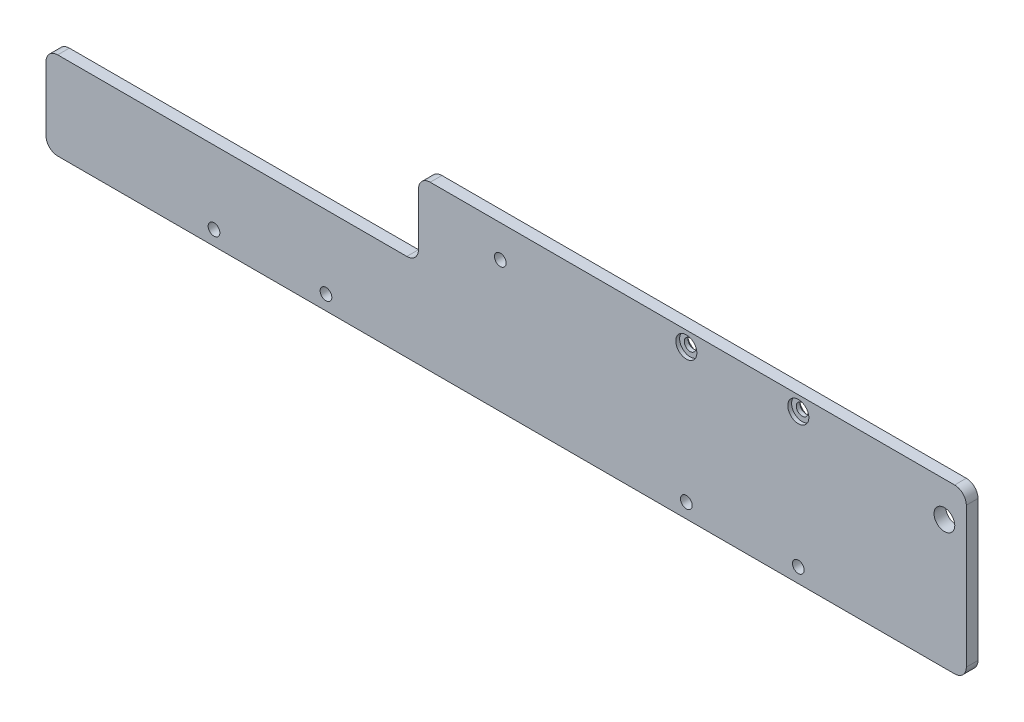
from build123d import *

# Parameters (mm, degrees)
SKETCH_1_R          = 2
SKETCH_1_R_2        = 3.55
EXTRUDE_1_DEPTH     = 4
EXTRUDE_3_DEPTH     = 4
SKETCH_3_R          = 3.6
CUT_EXTRUDE_1_DEPTH = 1.4
SKETCH_7_R          = 2
CUT_EXTRUDE_2_DEPTH = 10
SKETCH_8_R          = 3.6
CUT_EXTRUDE_3_DEPTH = 1.3


with BuildPart() as part:
    # 草图1 → 凸台-拉伸1 (new body)
    with BuildSketch(Plane.XY):
        with BuildLine():
            Line((-180.694062755, -12.410089261), (126.305937245, -12.410089261))
            ThreePointArc((126.305937245, -12.410089261), (129.13436437, -11.238516386), (130.305937245, -8.410089261))
            Line((130.305937245, -8.410089261), (130.305937245, 7.71191214))
            Line((130.305937245, 7.71191214), (130.305937245, 17.589910739))
            Line((130.305937245, 17.589910739), (130.305937245, 39.589910739))
            ThreePointArc((130.305937245, 39.589910739), (129.13436437, 42.418337863), (126.305937245, 43.589910739))
            Line((126.305937245, 43.589910739), (-23.194062755, 43.589910739))
            ThreePointArc((-23.194062755, 43.589910739), (-26.022489879, 42.418337863), (-27.194062755, 39.589910739))
            Line((-27.194062755, 39.589910739), (-27.194062755, 27.589910739))
            ThreePointArc((-27.194062755, 27.589910739), (-30.122994943, 20.518842927), (-37.194062755, 17.589910739))
            Line((-37.194062755, 17.589910739), (-180.694062755, 17.589910739))
            ThreePointArc((-180.694062755, 17.589910739), (-183.522489879, 16.418337863), (-184.694062755, 13.589910739))
            Line((-184.694062755, 13.589910739), (-184.694062755, -8.410089261))
            ThreePointArc((-184.694062755, -8.410089261), (-183.522489879, -11.238516386), (-180.694062755, -12.410089261))
        make_face()
        with Locations((-127.194062755, -7.410089261)):
            Circle(SKETCH_1_R, mode=Mode.SUBTRACT)
        with Locations((-88.864062755, -7.410089261)):
            Circle(SKETCH_1_R, mode=Mode.SUBTRACT)
        with Locations((34.475937245, -7.410089261)):
            Circle(SKETCH_1_R, mode=Mode.SUBTRACT)
        with Locations((72.805937245, -7.410089261)):
            Circle(SKETCH_1_R, mode=Mode.SUBTRACT)
        with Locations((34.475937245, 38.589910739)):
            Circle(SKETCH_1_R, mode=Mode.SUBTRACT)
        with Locations((122.805937245, 31.589910739)):
            Circle(SKETCH_1_R_2, mode=Mode.SUBTRACT)
        with Locations((72.805937245, 38.589910739)):
            Circle(SKETCH_1_R, mode=Mode.SUBTRACT)
    extrude(amount=EXTRUDE_1_DEPTH)

    # 草图2 → 凸台-拉伸3 (add)
    with BuildSketch(Plane(origin=(0, 0, 0), x_dir=(-1, 0, 0), z_dir=(0, 0, -1))):
        with BuildLine():
            Line((53.194062755, 43.589910739), (23.194062755, 43.589910739))
            Line((23.194062755, 43.589910739), (23.194062755, 17.589910739))
            Line((23.194062755, 17.589910739), (57.194062755, 17.589910739))
            Line((57.194062755, 17.589910739), (61.194062755, 17.589910739))
            ThreePointArc((61.194062755, 17.589910739), (58.36563563, 18.761483614), (57.194062755, 21.589910739))
            Line((57.194062755, 21.589910739), (57.194062755, 39.589910739))
            ThreePointArc((57.194062755, 39.589910739), (56.022489879, 42.418337863), (53.194062755, 43.589910739))
        make_face()
    extrude(amount=-EXTRUDE_3_DEPTH)

    # 草图3 → 切除-拉伸1 (cut)
    with BuildSketch(Plane(origin=(0, 0, 0), x_dir=(-1, 0, 0), z_dir=(0, 0, -1))):
        with Locations((-72.805937245, 38.589910739)):
            Circle(SKETCH_3_R)
        with Locations((-34.475937245, 38.589910739)):
            Circle(SKETCH_3_R)
    extrude(amount=-CUT_EXTRUDE_1_DEPTH, mode=Mode.SUBTRACT)

    # 草图7 → 切除-拉伸2 (cut)
    with BuildSketch(Plane(origin=(0, 0, 0), x_dir=(-1, 0, 0), z_dir=(0, 0, -1))):
        with Locations((29.194062755, 32.589910739)):
            Circle(SKETCH_7_R)
    extrude(amount=-CUT_EXTRUDE_2_DEPTH, mode=Mode.SUBTRACT)

    # 草图8 → 切除-拉伸3 (cut)
    with BuildSketch(Plane.XY.offset(4)):
        with Locations((72.805937245, 38.589910739)):
            Circle(SKETCH_8_R)
        with Locations((34.475937245, 38.589910739)):
            Circle(SKETCH_8_R)
    extrude(amount=-CUT_EXTRUDE_3_DEPTH, mode=Mode.SUBTRACT)


solid = part.part
